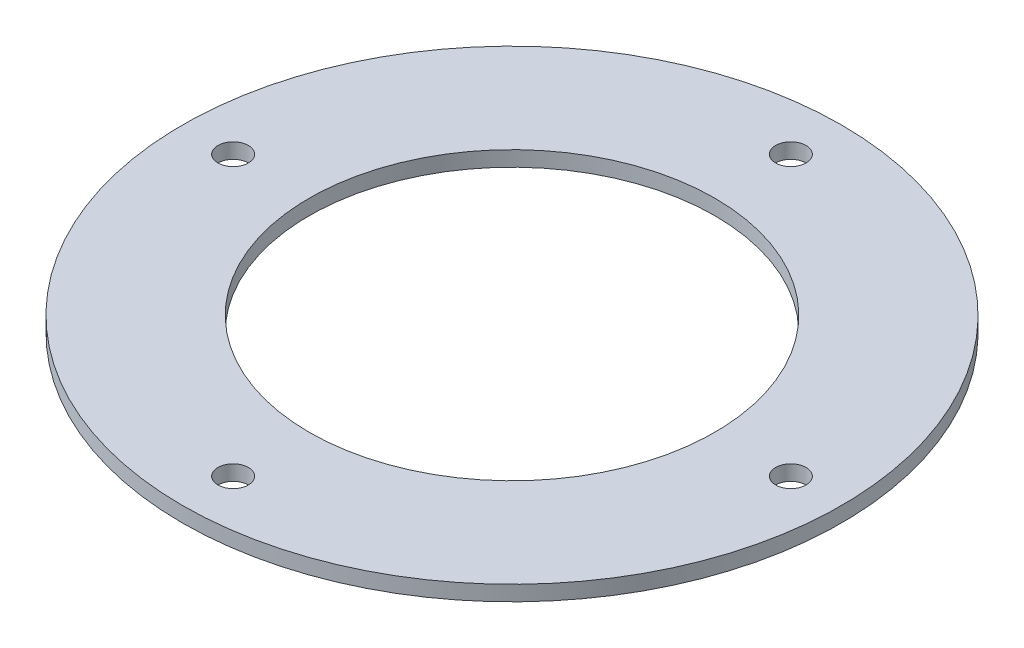
from build123d import *

# Parameters (mm, degrees)
SKETCH1_R           = 65
BOSS_EXTRUDE1_DEPTH = 3
SKETCH2_R           = 3
CUT_EXTRUDE1_DEPTH  = 4
CIRPATTERN1_COUNT   = 4
SKETCH3_R           = 40
CUT_EXTRUDE2_DEPTH  = 4


with BuildPart() as part:
    # Sketch1 → Boss-Extrude1 (new body)
    with BuildSketch(Plane(origin=(0, 0, 0), x_dir=(1, 0, 0), z_dir=(0, 1, 0))):
        Circle(SKETCH1_R)
    extrude(amount=BOSS_EXTRUDE1_DEPTH)

    # Sketch2 → Cut-Extrude1 (cut, through all)
    with BuildSketch(Plane(origin=(0, 3, 0), x_dir=(1, 0, 0), z_dir=(0, 1, 0))):
        with Locations((0, 55)):
            Circle(SKETCH2_R)
    cut_extrude1 = extrude(amount=-CUT_EXTRUDE1_DEPTH, mode=Mode.SUBTRACT)

    # CirPattern1: Cut-Extrude1 ×4 about axis
    cirpattern1_axis = Axis((0, 0, 0), (0, 1, 0))
    for i in range(1, CIRPATTERN1_COUNT):
        add(cut_extrude1.rotate(cirpattern1_axis, i * 360 / CIRPATTERN1_COUNT), mode=Mode.SUBTRACT)

    # Sketch3 → Cut-Extrude2 (cut, through all)
    with BuildSketch(Plane(origin=(0, 3, 0), x_dir=(1, 0, 0), z_dir=(0, 1, 0))):
        Circle(SKETCH3_R)
    extrude(amount=-CUT_EXTRUDE2_DEPTH, mode=Mode.SUBTRACT)


solid = part.part
